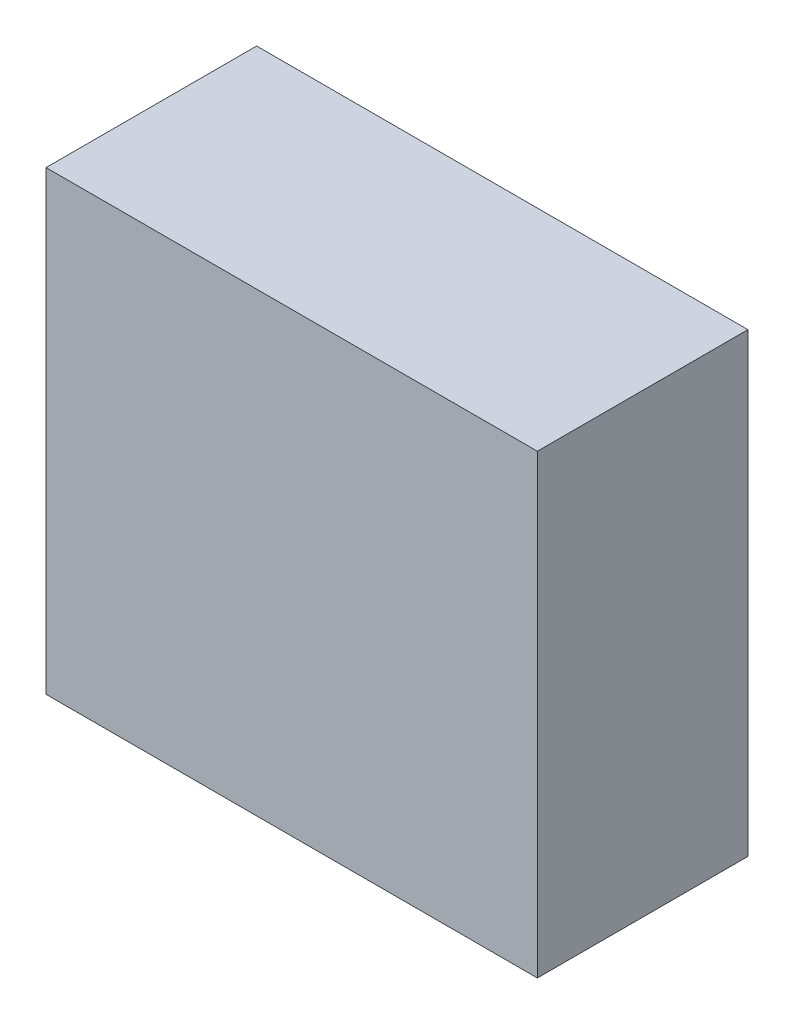
from build123d import *

# Parameters (mm, degrees)
SKETCH1_W           = 177.8
SKETCH1_H           = 76.2
BOSS_EXTRUDE1_DEPTH = 165.1


with BuildPart() as part:
    # Sketch1 → Boss-Extrude1 (new body)
    with BuildSketch(Plane(origin=(0, 0, 0), x_dir=(1, 0, 0), z_dir=(0, 1, 0))):
        with Locations((88.9, 38.1)):
            Rectangle(SKETCH1_W, SKETCH1_H)
    extrude(amount=BOSS_EXTRUDE1_DEPTH)


solid = part.part
